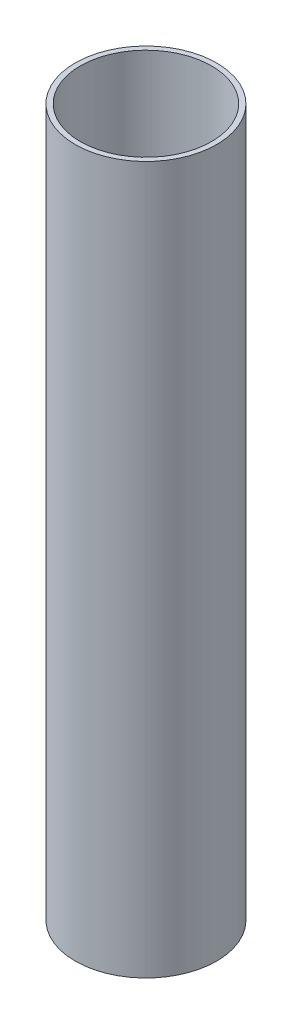
from build123d import *

# Parameters (mm, degrees)
SKETCH1_R           = 25
SKETCH1_R_2         = 23.2
BOSS_EXTRUDE1_DEPTH = 125


with BuildPart() as part:
    # Sketch1 → Boss-Extrude1 (new body, symmetric)
    with BuildSketch(Plane(origin=(0, 0, 0), x_dir=(1, 0, 0), z_dir=(0, 1, 0))):
        Circle(SKETCH1_R)
        Circle(SKETCH1_R_2, mode=Mode.SUBTRACT)
    extrude(amount=BOSS_EXTRUDE1_DEPTH, both=True)


solid = part.part
